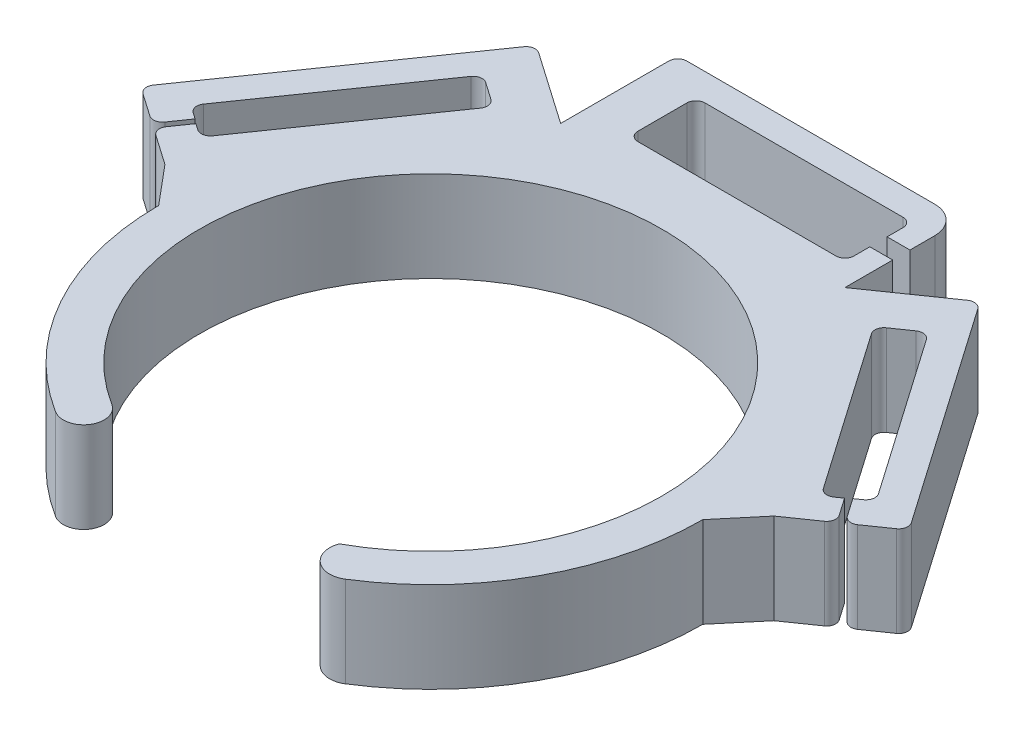
from build123d import *

# Parameters (mm, degrees)
BOSS_EXTRUDE1_DEPTH = 10


with BuildPart() as part:
    # Sketch1 → Boss-Extrude1 (new body)
    with BuildSketch(Plane(origin=(0, 0, 0), x_dir=(1, 0, 0), z_dir=(0, 1, 0))):
        with BuildLine():
            ThreePointArc((0, 30), (-13.892167355, 26.589616135), (-24.625826483, 17.133845746))
            ThreePointArc((-24.625826483, 17.133845746), (-28.62494362, 8.978452136), (-30, 0))
            ThreePointArc((-30, 0), (-26.261196487, -14.503432665), (-15.976696063, -25.391832996))
            ThreePointArc((-15.976696063, -25.391832996), (-12.874056383, -24.685697726), (-13.580191653, -21.583058047))
            ThreePointArc((-13.580191653, -21.583058047), (-12.327917765, 22.322017014), (25.5, 0))
            ThreePointArc((25.5, 0), (21.945347053, -12.986598583), (12.272412334, -22.352581406))
            ThreePointArc((12.272412334, -22.352581406), (13.029650018, -25.206692228), (15.976696063, -25.391832996))
            ThreePointArc((15.976696063, -25.391832996), (26.261196487, -14.503432665), (30, 0))
            ThreePointArc((30, 0), (28.624943418, 8.978452779), (24.625825713, 17.133846852))
            ThreePointArc((24.625825713, 17.133846852), (13.892166758, 26.589616447), (0, 30))
        make_face()
        with BuildLine():
            Line((-24.625826483, 17.133845746), (-33.577676267, 4.267691868))
            Line((-33.577676267, 4.267691868), (-30, 0))
            ThreePointArc((-30, 0), (-28.62494362, 8.978452136), (-24.625826483, 17.133845746))
        make_face()
        with BuildLine():
            Line((-36.964920826, 10.767390882), (-36.263797685, 10.279572292))
            Line((-36.263797685, 10.279572292), (-37.634960984, 8.308851333))
            ThreePointArc((-37.634960984, 8.308851333), (-38.27923419, 7.895694616), (-39.02695006, 8.059118652))
            Line((-39.02695006, 8.059118652), (-41.546608741, 9.812214895))
            ThreePointArc((-41.546608741, 9.812214895), (-41.959765459, 10.456488101), (-41.796341422, 11.204203971))
            Line((-41.796341422, 11.204203971), (-25.034897988, 35.294790347))
            ThreePointArc((-25.034897988, 35.294790347), (-24.390624781, 35.707947064), (-23.642908912, 35.544523027))
            Line((-23.642908912, 35.544523027), (-15.673976437, 30))
            Line((-15.673976437, 30), (-33.577676267, 4.267691868))
            Line((-33.577676267, 4.267691868), (-36.855117659, 6.548028579))
            ThreePointArc((-36.855117659, 6.548028579), (-37.268274376, 7.192301785), (-37.104850339, 7.940017655))
            Line((-37.104850339, 7.940017655), (-35.764584616, 9.866330702))
            Line((-35.764584616, 9.866330702), (-35.063461475, 9.378512113))
            ThreePointArc((-35.063461475, 9.378512113), (-34.315745606, 9.215088076), (-33.671472399, 9.628244793))
            Line((-33.671472399, 9.628244793), (-21.548947673, 27.051489405))
            ThreePointArc((-21.548947673, 27.051489405), (-21.385523636, 27.799205275), (-21.798680354, 28.443478482))
            Line((-21.798680354, 28.443478482), (-23.731037279, 29.787949338))
            ThreePointArc((-23.731037279, 29.787949338), (-24.478753149, 29.951373375), (-25.123026356, 29.538216658))
            Line((-25.123026356, 29.538216658), (-37.214653506, 12.159379958))
            ThreePointArc((-37.214653506, 12.159379958), (-37.378077543, 11.411664088), (-36.964920826, 10.767390882))
        make_face()
        with BuildLine():
            Line((-10.673976437, 33.521405271), (-10.673976437, 38.918895687))
            ThreePointArc((-10.673976437, 38.918895687), (-10.381083218, 39.626002468), (-9.673976437, 39.918895687))
            Line((-9.673976437, 39.918895687), (12.155554915, 39.918895687))
            ThreePointArc((12.155554915, 39.918895687), (12.862661696, 39.626002468), (13.155554915, 38.918895687))
            Line((13.155554915, 38.918895687), (13.155554915, 37.173234143))
            Line((13.155554915, 37.173234143), (15.673976437, 37.173234143))
            Line((15.673976437, 37.173234143), (15.673976437, 39.918895687))
            ThreePointArc((15.673976437, 39.918895687), (14.795296781, 42.040216031), (12.673976437, 42.918895687))
            Line((12.673976437, 42.918895687), (-14.673976437, 42.918895687))
            ThreePointArc((-14.673976437, 42.918895687), (-15.381083218, 42.626002468), (-15.673976437, 41.918895687))
            Line((-15.673976437, 41.918895687), (-15.673976437, 30))
            Line((-15.673976437, 30), (0, 30))
            Line((0, 30), (15.673976437, 30))
            Line((15.673976437, 30), (15.673976437, 35.267066815))
            Line((15.673976437, 35.267066815), (13.155554915, 35.267066815))
            Line((13.155554915, 35.267066815), (13.155554915, 33.521405271))
            ThreePointArc((13.155554915, 33.521405271), (12.862661696, 32.81429849), (12.155554915, 32.521405271))
            Line((12.155554915, 32.521405271), (-9.673976437, 32.521405271))
            ThreePointArc((-9.673976437, 32.521405271), (-10.381083218, 32.81429849), (-10.673976437, 33.521405271))
        make_face()
        with BuildLine():
            ThreePointArc((37.104850339, 7.940017655), (37.268274376, 7.192301785), (36.855117659, 6.548028579))
            Line((36.855117659, 6.548028579), (33.577676267, 4.267691868))
            Line((33.577676267, 4.267691868), (15.673976437, 30))
            Line((15.673976437, 30), (23.642908912, 35.544523027))
            ThreePointArc((23.642908912, 35.544523027), (24.390624781, 35.707947064), (25.034897988, 35.294790347))
            Line((25.034897988, 35.294790347), (41.796341422, 11.204203971))
            ThreePointArc((41.796341422, 11.204203971), (41.959765459, 10.456488101), (41.546608741, 9.812214895))
            Line((41.546608741, 9.812214895), (39.02695006, 8.059118652))
            ThreePointArc((39.02695006, 8.059118652), (38.27923419, 7.895694616), (37.634960984, 8.308851333))
            Line((37.634960984, 8.308851333), (36.263797685, 10.279572292))
            Line((36.263797685, 10.279572292), (36.964920826, 10.767390882))
            ThreePointArc((36.964920826, 10.767390882), (37.378077543, 11.411664088), (37.214653506, 12.159379958))
            Line((37.214653506, 12.159379958), (25.123026356, 29.538216658))
            ThreePointArc((25.123026356, 29.538216658), (24.478753149, 29.951373375), (23.731037279, 29.787949338))
            Line((23.731037279, 29.787949338), (21.798680354, 28.443478482))
            ThreePointArc((21.798680354, 28.443478482), (21.385523636, 27.799205275), (21.548947673, 27.051489405))
            Line((21.548947673, 27.051489405), (33.671472399, 9.628244793))
            ThreePointArc((33.671472399, 9.628244793), (34.315745606, 9.215088076), (35.063461475, 9.378512113))
            Line((35.063461475, 9.378512113), (35.764584616, 9.866330702))
            Line((35.764584616, 9.866330702), (37.104850339, 7.940017655))
        make_face()
        with BuildLine():
            Line((-15.673976437, 30), (-24.625826483, 17.133845746))
            ThreePointArc((-24.625826483, 17.133845746), (-13.892167355, 26.589616135), (0, 30))
            Line((0, 30), (-15.673976437, 30))
        make_face()
        with BuildLine():
            Line((15.673976437, 30), (0, 30))
            ThreePointArc((0, 30), (13.892166758, 26.589616447), (24.625825713, 17.133846852))
            Line((24.625825713, 17.133846852), (15.673976437, 30))
        make_face()
        with BuildLine():
            Line((33.577676267, 4.267691868), (24.625825713, 17.133846852))
            ThreePointArc((24.625825713, 17.133846852), (28.624943418, 8.978452779), (30, 0))
            Line((30, 0), (33.577676267, 4.267691868))
        make_face()
    extrude(amount=BOSS_EXTRUDE1_DEPTH)


solid = part.part
